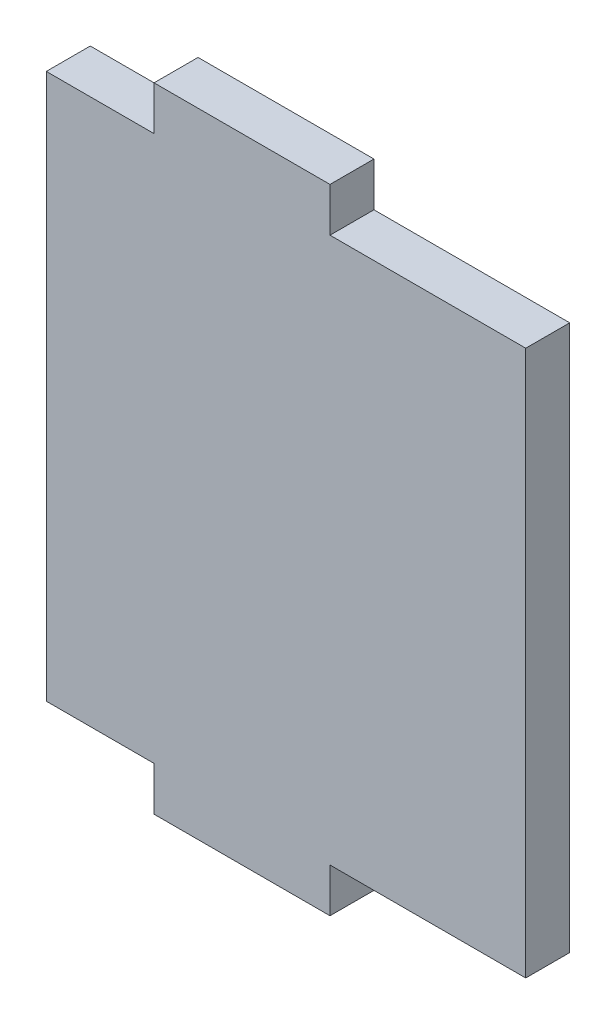
from build123d import *

# Parameters (mm, degrees)
BOSS_EXTRUDE1_DEPTH = 5


with BuildPart() as part:
    # Sketch1 → Boss-Extrude1 (new body)
    with BuildSketch(Plane.XY):
        Polygon((5, 31), (5, 36), (-15, 36), (-15, 31), (-27.25, 31), (-27.25, -31), (-15, -31), (-15, -36), (5, -36), (5, -31), (27.25, -31), (27.25, 31), align=None)
    extrude(amount=BOSS_EXTRUDE1_DEPTH)


solid = part.part
